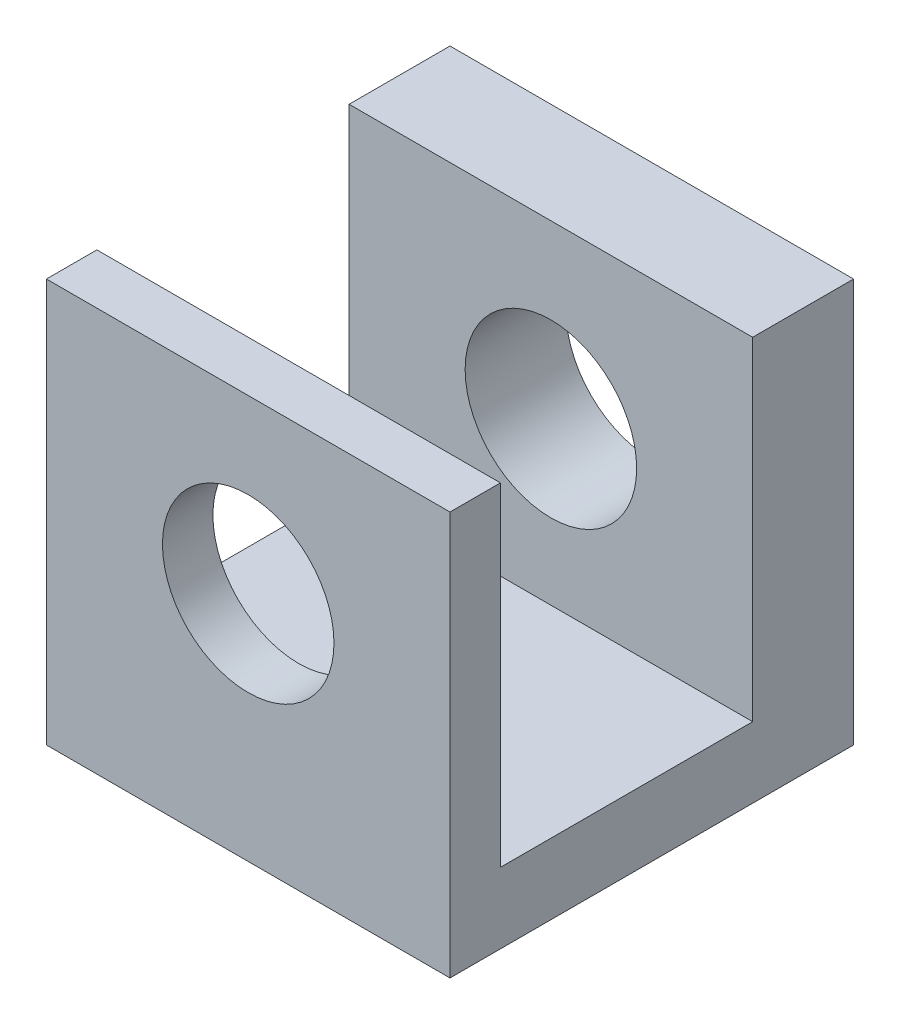
from build123d import *

# Parameters (mm, degrees)
SKETCH1_W           = 40
SKETCH1_H           = 40
BOSS_EXTRUDE1_DEPTH = 40
SKETCH2_W           = 25
SKETCH2_H           = 33
CUT_EXTRUDE1_DEPTH  = 62.5
SKETCH3_R           = 8.5
CUT_EXTRUDE2_DEPTH  = 62.5


with BuildPart() as part:
    # Sketch1 → Boss-Extrude1 (new body)
    with BuildSketch(Plane.XY):
        Rectangle(SKETCH1_W, SKETCH1_H)
    extrude(amount=-BOSS_EXTRUDE1_DEPTH)

    # Sketch2 → Cut-Extrude1 (cut)
    with BuildSketch(Plane(origin=(20, 0, 0), x_dir=(0, 0, -1), z_dir=(1, 0, 0))):
        with Locations((17.5, 3.5)):
            Rectangle(SKETCH2_W, SKETCH2_H)
    extrude(amount=-CUT_EXTRUDE1_DEPTH, mode=Mode.SUBTRACT)

    # Sketch3 → Cut-Extrude2 (cut)
    with BuildSketch(Plane.XY):
        with Locations((0, 2.994290039)):
            Circle(SKETCH3_R)
    extrude(amount=-CUT_EXTRUDE2_DEPTH, mode=Mode.SUBTRACT)


solid = part.part
